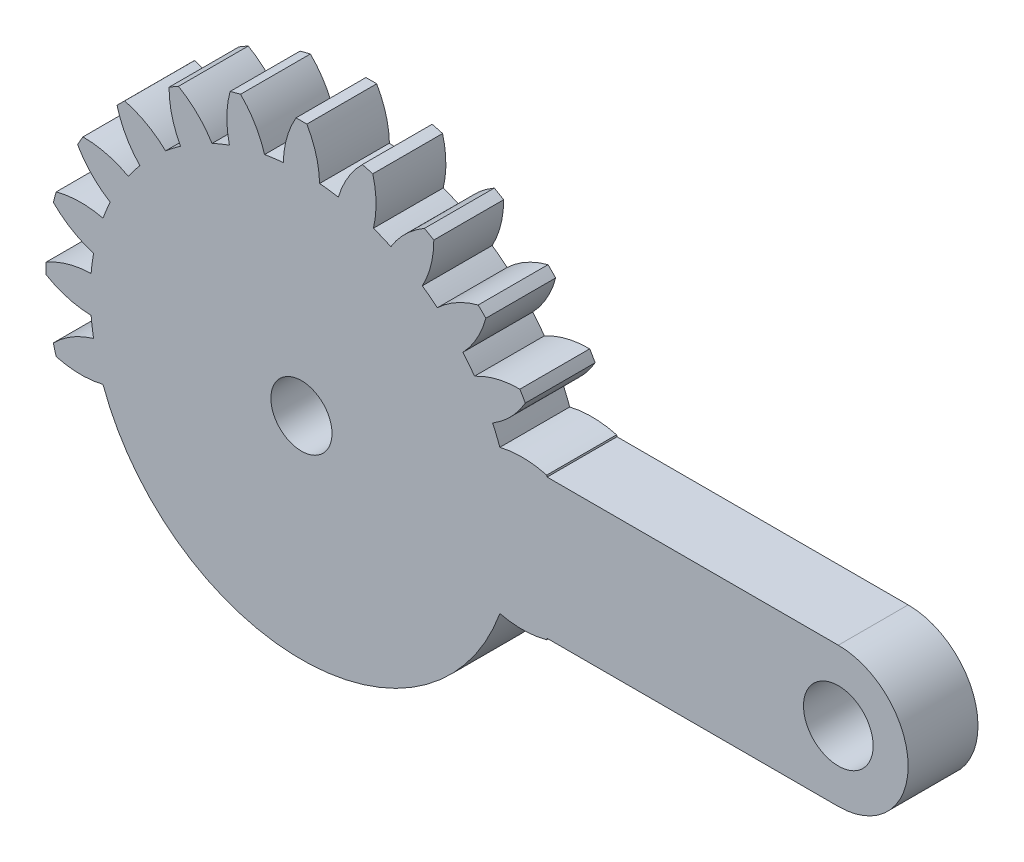
from build123d import *

# Parameters (mm, degrees)
SKETCH2_R           = 1750
SKETCH2_R_2         = 1995
BOSS_EXTRUDE1_DEPTH = 4000


with BuildPart() as part:
    # Sketch2 → Boss-Extrude1 (new body)
    with BuildSketch(Plane.XY):
        with BuildLine():
            Line((14072.558402792, -4000), (30750, -4000))
            ThreePointArc((30750, -4000), (34750, 0), (30750, 4000))
            Line((30750, 4000), (14072.558402792, 4000))
            ThreePointArc((14072.558402792, 4000), (14060.387670314, 4042.573259754), (14048.088142637, 4085.109488948))
            ThreePointArc((14048.088142637, 4085.109488948), (12709.169027193, 4272.836062793), (11365.584201411, 4122.086335903))
            ThreePointArc((11365.584201411, 4122.086335903), (11169.703548061, 4626.642697294), (10951.436861718, 5121.926460211))
            ThreePointArc((10951.436861718, 5121.926460211), (12008.090957274, 5965.388247475), (12822.10700989, 7044.889766841))
            ThreePointArc((12822.10700989, 7044.889766841), (12669.951657366, 7315), (12512.10700989, 7581.825517187))
            ThreePointArc((12512.10700989, 7581.825517187), (11170.223244387, 7416.617696216), (9911.436861718, 6923.259300083))
            ThreePointArc((9911.436861718, 6923.259300083), (9591.641884121, 7359.925676715), (9252.62358419, 7781.841479322))
            ThreePointArc((9252.62358419, 7781.841479322), (10054.969090182, 8870.045207143), (10561.852665989, 10123.446461653))
            ThreePointArc((10561.852665989, 10123.446461653), (10344.972208759, 10344.972208759), (10123.446461653, 10561.852665989))
            ThreePointArc((10123.446461653, 10561.852665989), (8870.045207143, 10054.969090182), (7781.841479322, 9252.62358419))
            ThreePointArc((7781.841479322, 9252.62358419), (7359.925676715, 9591.641884121), (6923.259300083, 9911.436861718))
            ThreePointArc((6923.259300083, 9911.436861718), (7416.617696216, 11170.223244387), (7581.825517187, 12512.10700989))
            ThreePointArc((7581.825517187, 12512.10700989), (7315, 12669.951657366), (7044.889766841, 12822.10700989))
            ThreePointArc((7044.889766841, 12822.10700989), (5965.388247475, 12008.090957274), (5121.926460211, 10951.436861718))
            ThreePointArc((5121.926460211, 10951.436861718), (4626.642697294, 11169.703548061), (4122.086335903, 11365.584201411))
            ThreePointArc((4122.086335903, 11365.584201411), (4272.836062793, 12709.169027193), (4085.109488948, 14048.088142637))
            ThreePointArc((4085.109488948, 14048.088142637), (3786.52262985, 14131.494838609), (3486.235476649, 14208.555950601))
            ThreePointArc((3486.235476649, 14208.555950601), (2654.199937011, 13142.881269936), (2112.960617221, 11903.927815224))
            ThreePointArc((2112.960617221, 11903.927815224), (1578.06166394, 11986.568374009), (1040, 12045.185760294))
            ThreePointArc((1040, 12045.185760294), (837.867712887, 13382.005943691), (310, 14626.715284027))
            ThreePointArc((310, 14626.715284027), (0, 14630), (-310, 14626.715284027))
            ThreePointArc((-310, 14626.715284027), (-837.867712887, 13382.005943691), (-1040, 12045.185760294))
            ThreePointArc((-1040, 12045.185760294), (-1578.06166394, 11986.568374009), (-2112.960617221, 11903.927815224))
            ThreePointArc((-2112.960617221, 11903.927815224), (-2654.199937011, 13142.881269936), (-3486.235476649, 14208.555950601))
            ThreePointArc((-3486.235476649, 14208.555950601), (-3786.52262985, 14131.494838609), (-4085.109488948, 14048.088142637))
            ThreePointArc((-4085.109488948, 14048.088142637), (-4272.836062793, 12709.169027193), (-4122.086335903, 11365.584201411))
            ThreePointArc((-4122.086335903, 11365.584201411), (-4626.642697294, 11169.703548061), (-5121.926460211, 10951.436861718))
            ThreePointArc((-5121.926460211, 10951.436861718), (-5965.388247475, 12008.090957274), (-7044.889766841, 12822.10700989))
            ThreePointArc((-7044.889766841, 12822.10700989), (-7315, 12669.951657366), (-7581.825517187, 12512.10700989))
            ThreePointArc((-7581.825517187, 12512.10700989), (-7416.617696216, 11170.223244387), (-6923.259300083, 9911.436861718))
            ThreePointArc((-6923.259300083, 9911.436861718), (-7359.925676715, 9591.641884121), (-7781.841479322, 9252.62358419))
            ThreePointArc((-7781.841479322, 9252.62358419), (-8870.045207143, 10054.969090182), (-10123.446461653, 10561.852665989))
            ThreePointArc((-10123.446461653, 10561.852665989), (-10344.972208759, 10344.972208759), (-10561.852665989, 10123.446461653))
            ThreePointArc((-10561.852665989, 10123.446461653), (-10054.969090182, 8870.045207143), (-9252.62358419, 7781.841479322))
            ThreePointArc((-9252.62358419, 7781.841479322), (-9591.641884121, 7359.925676715), (-9911.436861718, 6923.259300083))
            ThreePointArc((-9911.436861718, 6923.259300083), (-11170.223244387, 7416.617696216), (-12512.10700989, 7581.825517187))
            ThreePointArc((-12512.10700989, 7581.825517187), (-12669.951657366, 7315), (-12822.10700989, 7044.889766841))
            ThreePointArc((-12822.10700989, 7044.889766841), (-12008.090957274, 5965.388247475), (-10951.436861718, 5121.926460211))
            ThreePointArc((-10951.436861718, 5121.926460211), (-11169.703548061, 4626.642697294), (-11365.584201411, 4122.086335903))
            ThreePointArc((-11365.584201411, 4122.086335903), (-12709.169027193, 4272.836062793), (-14048.088142637, 4085.109488948))
            ThreePointArc((-14048.088142637, 4085.109488948), (-14131.494838609, 3786.52262985), (-14208.555950601, 3486.235476649))
            ThreePointArc((-14208.555950601, 3486.235476649), (-13142.881269936, 2654.199937011), (-11903.927815224, 2112.960617221))
            ThreePointArc((-11903.927815224, 2112.960617221), (-11986.568374009, 1578.06166394), (-12045.185760294, 1040))
            ThreePointArc((-12045.185760294, 1040), (-13382.005943691, 837.867712887), (-14626.715284027, 310))
            ThreePointArc((-14626.715284027, 310), (-14630, 0), (-14626.715284027, -310))
            ThreePointArc((-14626.715284027, -310), (-13382.005943691, -837.867712887), (-12045.185760294, -1040))
            ThreePointArc((-12045.185760294, -1040), (-11986.568374009, -1578.06166394), (-11903.927815224, -2112.960617221))
            ThreePointArc((-11903.927815224, -2112.960617221), (-13142.881269936, -2654.199937011), (-14208.555950601, -3486.235476649))
            ThreePointArc((-14208.555950601, -3486.235476649), (-14131.494838609, -3786.52262985), (-14048.088142637, -4085.109488948))
            ThreePointArc((-14048.088142637, -4085.109488948), (-12709.169027193, -4272.836062793), (-11365.584201411, -4122.086335903))
            ThreePointArc((-11365.584201411, -4122.086335903), (0, -12090), (11365.584201411, -4122.086335903))
            ThreePointArc((11365.584201411, -4122.086335903), (12709.169027193, -4272.836062793), (14048.088142637, -4085.109488948))
            ThreePointArc((14048.088142637, -4085.109488948), (14060.387670314, -4042.573259754), (14072.558402792, -4000))
        make_face()
        Circle(SKETCH2_R, mode=Mode.SUBTRACT)
        with Locations((30750, 0)):
            Circle(SKETCH2_R_2, mode=Mode.SUBTRACT)
    extrude(amount=BOSS_EXTRUDE1_DEPTH)


solid = part.part
